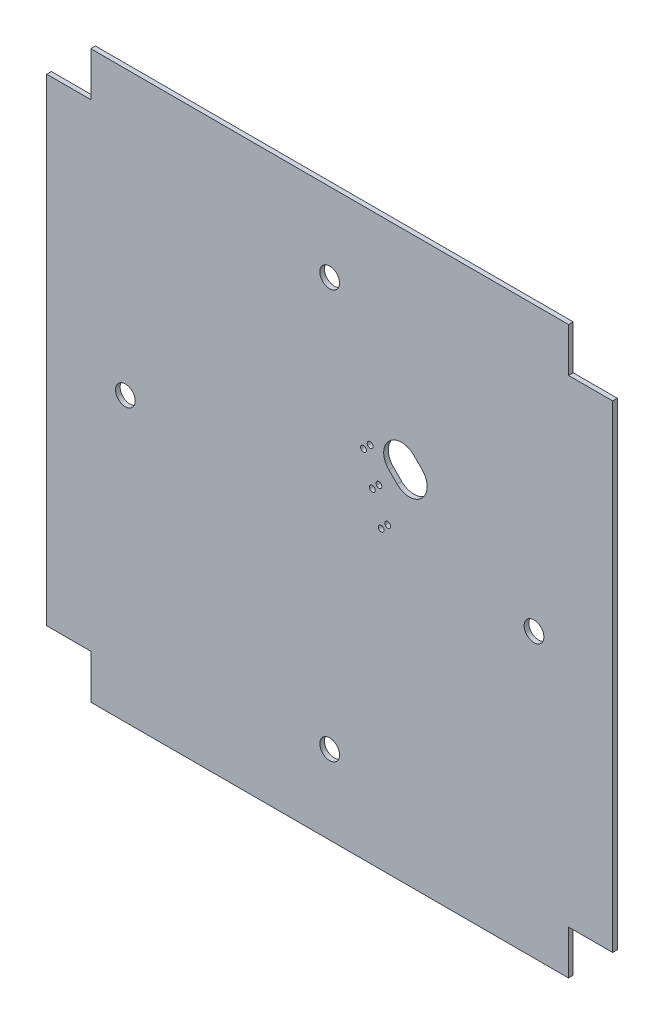
from build123d import *

# Parameters (mm, degrees)
SKETCH1_W           = 97.5
SKETCH1_H           = 97.5
BOSS_EXTRUDE1_DEPTH = 0.8
SKETCH2_W           = 7.6
SKETCH2_H           = 7.6
CUT_EXTRUDE1_DEPTH  = 1.8
SKETCH3_R           = 1.7
CUT_EXTRUDE2_DEPTH  = 1.8
CUT_EXTRUDE3_DEPTH  = 1.8
SKETCH5_R           = 0.5
CUT_EXTRUDE4_DEPTH  = 1.8
FILLET2_R           = 3


with BuildPart() as part:
    # Sketch1 → Boss-Extrude1 (new body)
    with BuildSketch(Plane.XY):
        Rectangle(SKETCH1_W, SKETCH1_H)
    extrude(amount=BOSS_EXTRUDE1_DEPTH)

    # Sketch2 → Cut-Extrude1 (cut, through all)
    with BuildSketch(Plane(origin=(0, 0, 0), x_dir=(-1, 0, 0), z_dir=(0, 0, -1))):
        with Locations((-44.95, 44.95)):
            Rectangle(SKETCH2_W, SKETCH2_H)
        with Locations((-44.95, -44.95)):
            Rectangle(SKETCH2_W, SKETCH2_H)
        with Locations((44.95, -44.95)):
            Rectangle(SKETCH2_W, SKETCH2_H)
        with Locations((44.95, 44.95)):
            Rectangle(SKETCH2_W, SKETCH2_H)
    extrude(amount=-CUT_EXTRUDE1_DEPTH, mode=Mode.SUBTRACT)

    # Sketch3 → Cut-Extrude2 (cut, through all)
    with BuildSketch(Plane(origin=(0, 0, 0), x_dir=(-1, 0, 0), z_dir=(0, 0, -1))):
        with Locations((0, 35.2)):
            Circle(SKETCH3_R)
        with Locations((35.2, 0)):
            Circle(SKETCH3_R)
        with Locations((0, -35.2)):
            Circle(SKETCH3_R)
        with Locations((-35.2, 0)):
            Circle(SKETCH3_R)
    extrude(amount=-CUT_EXTRUDE2_DEPTH, mode=Mode.SUBTRACT)

    # Sketch4 → Cut-Extrude3 (cut, through all)
    with BuildSketch(Plane(origin=(0, 0, 0), x_dir=(-1, 0, 0), z_dir=(0, 0, -1))):
        Polygon((-18.03122292, 12.374368671), (-13.717871555, 8.061017306), (-8.061017306, 13.717871555), (-12.374368671, 18.03122292), align=None)
    extrude(amount=-CUT_EXTRUDE3_DEPTH, mode=Mode.SUBTRACT)

    # Sketch5 → Cut-Extrude4 (cut, through all)
    with BuildSketch(Plane(origin=(0, 0, 0), x_dir=(-1, 0, 0), z_dir=(0, 0, -1))):
        with Locations((-6.965001795, 13.682516216)):
            Circle(SKETCH5_R)
        with Locations((-5.833630945, 12.551145366)):
            Circle(SKETCH5_R)
        with Locations((-8.485281374, 8.485281374)):
            Circle(SKETCH5_R)
        with Locations((-7.353910524, 7.353910524)):
            Circle(SKETCH5_R)
        with Locations((-10.005560954, 3.288046533)):
            Circle(SKETCH5_R)
        with Locations((-8.874190104, 2.156675683)):
            Circle(SKETCH5_R)
    extrude(amount=-CUT_EXTRUDE4_DEPTH, mode=Mode.SUBTRACT)

    # Fillet2
    fillet2_edges = [part.edges().sort_by_distance(p)[0] for p in [
        (18.03122292, 12.374368671, 0.4),
        (12.374368671, 18.03122292, 0.4),
        (8.061017306, 13.717871555, 0.4),
        (13.717871555, 8.061017306, 0.4),
    ]]
    fillet(fillet2_edges, radius=FILLET2_R)


solid = part.part
